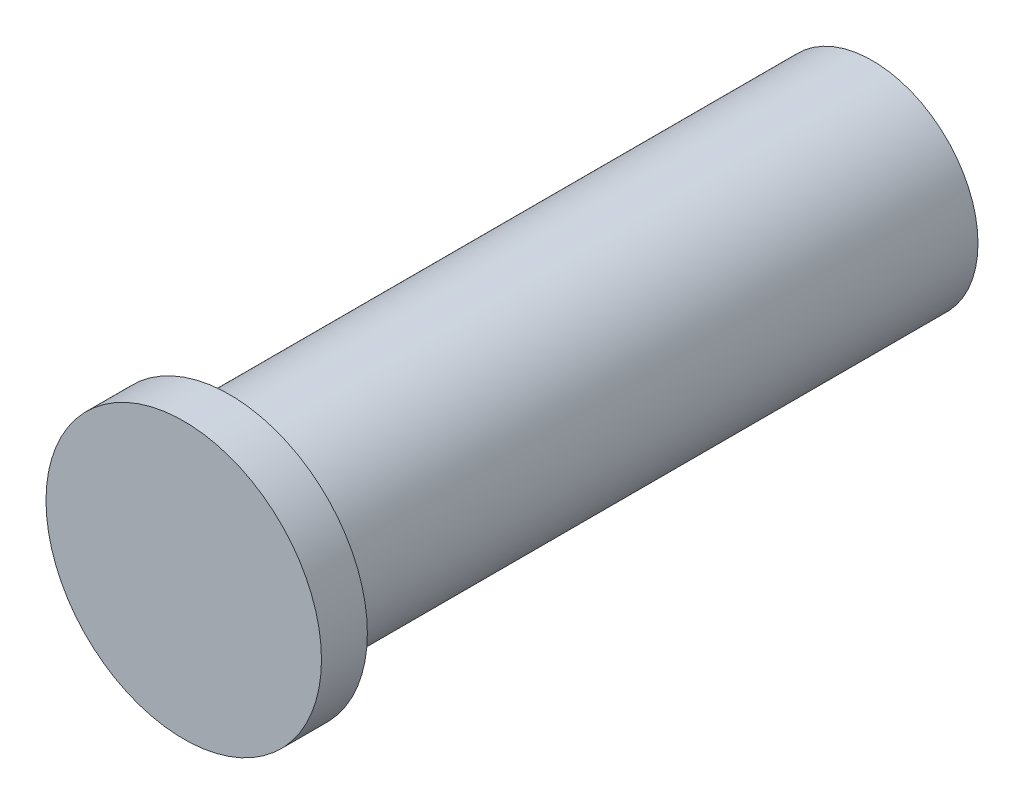
from build123d import *

# Parameters (mm, degrees)
SKETCH1_R           = 2.3
BOSS_EXTRUDE1_DEPTH = 14
SKETCH2_R           = 3
BOSS_EXTRUDE2_DEPTH = 1


with BuildPart() as part:
    # Sketch1 → Boss-Extrude1 (new body)
    with BuildSketch(Plane.XY):
        Circle(SKETCH1_R)
    extrude(amount=BOSS_EXTRUDE1_DEPTH)

    # Sketch2 → Boss-Extrude2 (add)
    with BuildSketch(Plane.XY.offset(14)):
        Circle(SKETCH2_R)
    extrude(amount=BOSS_EXTRUDE2_DEPTH)


solid = part.part
